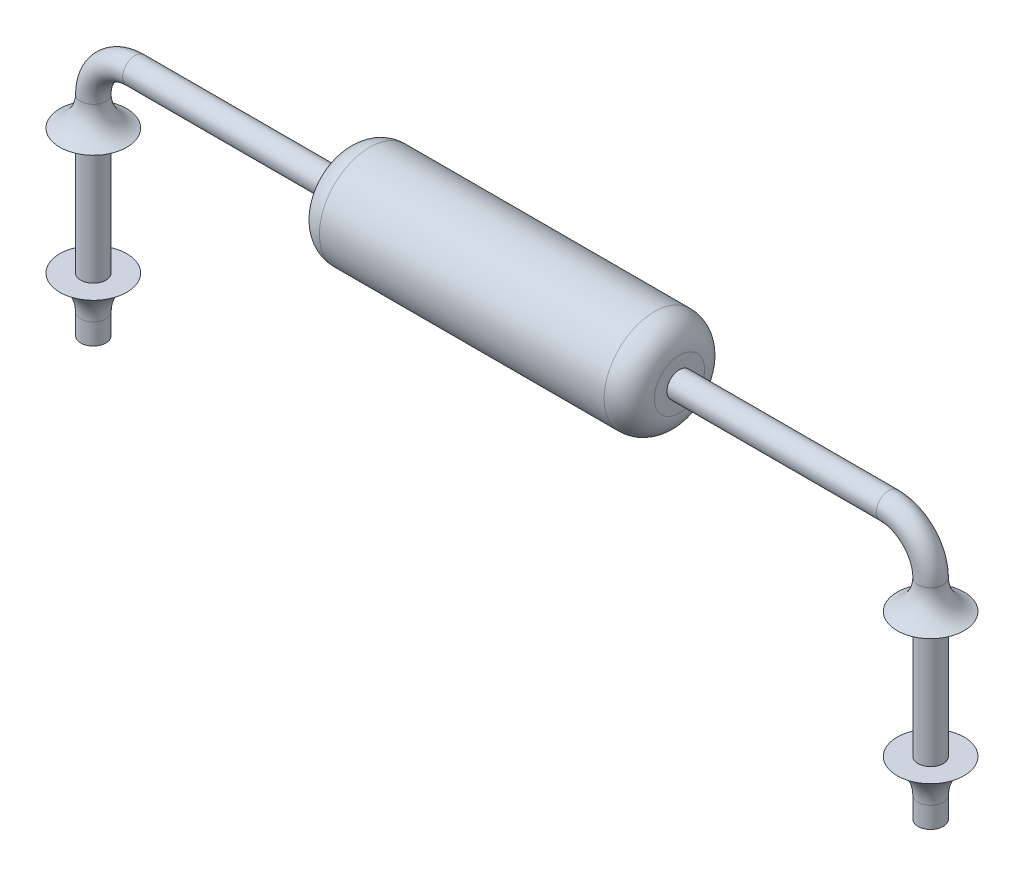
from build123d import *

# Parameters (mm, degrees)
SKETCH1_W               = 3.5
SKETCH1_H               = 0.35
FILLET1_R               = 0.1
SKETCH2_W               = 1.1
SKETCH2_H               = 0.55
SKETCH3_R               = 0.15
SKETCH6_W               = 12
SKETCH6_H               = 5
CUT_EXTRUDE1_DEPTH      = 1.6000001
CUT_EXTRUDE1_DEPTH_BACK = 1.6000001


with BuildPart() as part:
    # Sketch1 → Base-Revolve (revolve)
    with BuildSketch(Plane.XY, mode=Mode.PRIVATE) as base_revolve_sk:
        with Locations((0, 0.175)):
            Rectangle(SKETCH1_W, SKETCH1_H)
    revolve(base_revolve_sk.sketch.rotate(Axis((-19.951848249, 0, 0), (1, 0, 0)), 90), axis=Axis((-19.951848249, 0, 0), (1, 0, 0)))  # turned: the seam where the file's is

    # Fillet1
    fillet1_edges = [part.edges().sort_by_distance(p)[0] for p in [
        (1.75, 0, -0.35),
        (-1.75, 0, -0.35),
    ]]
    fillet(fillet1_edges, radius=FILLET1_R)

    # Sketch2 → Boss-Revolve1 (revolve)
    with BuildSketch(Plane.XY, mode=Mode.PRIVATE) as boss_revolve1_sk:
        with Locations((0.7, 0.275)):
            Rectangle(SKETCH2_W, SKETCH2_H)
    revolve(boss_revolve1_sk.sketch.rotate(Axis((0, 0, 0), (1, 0, 0)), 90), axis=Axis((0, 0, 0), (1, 0, 0)))  # turned: the seam where the file's is

    # Boss-Sweep1: sweep along a path in Sketch4
    with BuildLine(Plane.XY) as boss_sweep1_path:
        Line((0, -7), (-4.5, -7))
        ThreePointArc((-4.5, -7), (-4.853553391, -6.853553391), (-5, -6.5))
        Line((-5, -6.5), (-5, -0.5))
        ThreePointArc((-5, -0.5), (-4.853553391, -0.146446609), (-4.5, 0))
        Line((-4.5, 0), (4.5, 0))
        ThreePointArc((4.5, 0), (4.853553391, -0.146446609), (5, -0.5))
        Line((5, -0.5), (5, -6.5))
        ThreePointArc((5, -6.5), (4.853553391, -6.853553391), (4.5, -7))
        Line((4.5, -7), (0, -7))
    # Sketch3 → Boss-Sweep1 (sweep)
    with BuildSketch(Plane(origin=(0, 0, 0), x_dir=(0, 0, -1), z_dir=(1, 0, 0))):
        with Locations((0, -7)):
            Circle(SKETCH3_R)
    sweep(path=boss_sweep1_path.line)

    # Sketch5 → Boss-Revolve2 (revolve)
    with BuildSketch(Plane.XY):
        with BuildLine():
            Line((-1.7, 0.6), (1.7, 0.6))
            ThreePointArc((1.7, 0.6), (1.912132034, 0.512132034), (2, 0.3))
            Line((2, 0.3), (2, 0))
            Line((2, 0), (1.955, 0))
            Line((1.955, 0), (1.955, 0.3))
            ThreePointArc((1.955, 0.3), (1.880312229, 0.480312229), (1.7, 0.555))
            Line((1.7, 0.555), (-1.7, 0.555))
            ThreePointArc((-1.7, 0.555), (-1.880312229, 0.480312229), (-1.955, 0.3))
            Line((-1.955, 0.3), (-1.955, 0))
            Line((-1.955, 0), (-2, 0))
            Line((-2, 0), (-2, 0.3))
            ThreePointArc((-2, 0.3), (-1.912132034, 0.512132034), (-1.7, 0.6))
        make_face()
    revolve(axis=Axis((2, 0, 0), (-1, 0, 0)))

    # Sketch6 → Cut-Extrude1 (cut, two sides)
    with BuildSketch(Plane.XY) as cut_extrude1_sk:
        with Locations((0, -5.5)):
            Rectangle(SKETCH6_W, SKETCH6_H)
    extrude(amount=CUT_EXTRUDE1_DEPTH, mode=Mode.SUBTRACT)
    extrude(cut_extrude1_sk.sketch, amount=-CUT_EXTRUDE1_DEPTH_BACK, mode=Mode.SUBTRACT)

    # Sketch7 → Revolve1 (revolve)
    with BuildSketch(Plane.XY, mode=Mode.PRIVATE) as revolve1_sk:
        with BuildLine():
            Line((-5.15, -0.85), (-5.4, -0.85))
            ThreePointArc((-5.4, -0.85), (-5.218918616, -0.715058132), (-5.15, -0.5))
            Line((-5.15, -0.5), (-5.15, -0.85))
        make_face()
        with BuildLine():
            Line((-5.15, -2.35), (-5.15, -2.75))
            ThreePointArc((-5.15, -2.75), (-5.217640755, -2.514150472), (-5.4, -2.35))
            Line((-5.4, -2.35), (-5.15, -2.35))
        make_face()
    revolve(revolve1_sk.sketch.rotate(Axis((-5, -0.5, 0), (0, -1, 0)), 270), axis=Axis((-5, -0.5, 0), (0, -1, 0)))  # turned: the seam where the file's is

    # Sketch8 → Revolve2 (revolve)
    with BuildSketch(Plane.XY):
        with BuildLine():
            Line((5.15, -0.85), (5.4, -0.85))
            ThreePointArc((5.4, -0.85), (5.218918616, -0.715058132), (5.15, -0.5))
            Line((5.15, -0.5), (5.15, -0.85))
        make_face()
        with BuildLine():
            Line((5.15, -2.35), (5.4, -2.35))
            ThreePointArc((5.4, -2.35), (5.217640755, -2.514150472), (5.15, -2.75))
            Line((5.15, -2.75), (5.15, -2.35))
        make_face()
    revolve(axis=Axis((5, -0.5, 0), (0, -1, 0)))


solid = part.part
